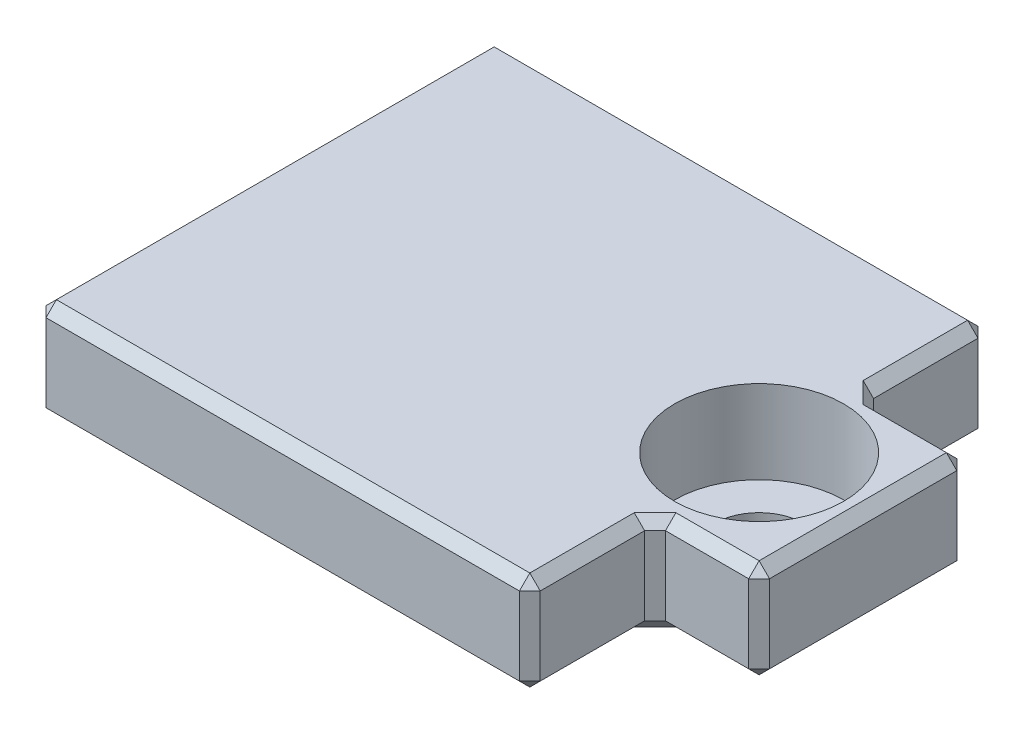
from build123d import *

# Parameters (mm, degrees)
SKETCH1_W                      = 13
SKETCH1_H                      = 8
BOSS_EXTRUDE1_DEPTH            = 3.8
SKETCH2_R                      = 0.95
BOSS_EXTRUDE2_DEPTH            = 5.6
BOSS_EXTRUDE5_DEPTH            = 3.8
CBORE_FOR_M3_SHCS1_D           = 3.4
CBORE_FOR_M3_SHCS1_CBORE_D     = 6.5
CBORE_FOR_M3_SHCS1_CBORE_DEPTH = 3.2
CHAMFER4_SIZE                  = 0.4


with BuildPart() as part:
    # Sketch1 → Boss-Extrude1 (new body)
    with BuildSketch(Plane(origin=(0, 0, 0), x_dir=(1, 0, 0), z_dir=(0, 1, 0))):
        Rectangle(SKETCH1_W, SKETCH1_H)
    extrude(amount=BOSS_EXTRUDE1_DEPTH)

    # Sketch2 → Boss-Extrude2 (add)
    with BuildSketch(Plane.XZ):
        with Locations((3.25, 1)):
            Circle(SKETCH2_R)
        with Locations((-3.25, 1)):
            Circle(SKETCH2_R)
    extrude(amount=BOSS_EXTRUDE2_DEPTH)

    # Sketch8 → Boss-Extrude5 (add)
    with BuildSketch(Plane(origin=(0, 3.8, 0), x_dir=(1, 0, 0), z_dir=(0, 1, 0))):
        Polygon((-9.5, -13.63), (9.5, -13.63), (9.5, -8.815), (13.5, -8.815), (13.5, -0.815), (9.5, -0.815), (9.5, 4), (-9.5, 4), align=None)
    extrude(amount=-BOSS_EXTRUDE5_DEPTH)

    # CBORE for M3 SHCS1 (through all)
    with Locations(Plane(origin=(0, 3.8, 0), x_dir=(1, 0, 0), z_dir=(0, 1, 0))):
        with Locations((9.5, -4.815)):
            CounterBoreHole(CBORE_FOR_M3_SHCS1_D / 2, CBORE_FOR_M3_SHCS1_CBORE_D / 2, CBORE_FOR_M3_SHCS1_CBORE_DEPTH)

    # Chamfer4
    chamfer4_edges = [part.edges().sort_by_distance(p)[0] for p in [
        (2.3, -5.6, 1),
        (-4.2, -5.6, 1),
        (-9.5, 3.8, 4.815),
        (0, 3.8, 13.63),
        (9.5, 3.8, 11.2225),
        (11.5, 3.8, 8.815),
        (13.5, 3.8, 4.815),
        (11.5, 3.8, 0.815),
        (9.5, 3.8, -1.5925),
        (-9.5, 1.9, -4),
        (-9.5, 0, 4.815),
        (-9.5, 1.9, 13.63),
        (0, 0, 13.63),
        (9.5, 1.9, 13.63),
        (9.5, 0, 11.2225),
        (9.5, 1.9, 8.815),
        (11.5, 0, 8.815),
        (13.5, 1.9, 8.815),
        (13.5, 0, 4.815),
        (13.5, 1.9, 0.815),
        (11.5, 0, 0.815),
        (9.5, 1.9, 0.815),
        (9.5, 0, -1.5925),
        (9.5, 1.9, -4),
        (0, 0, -4),
        (0, 3.8, -4),
    ]]
    chamfer(chamfer4_edges, length=CHAMFER4_SIZE)


solid = part.part
